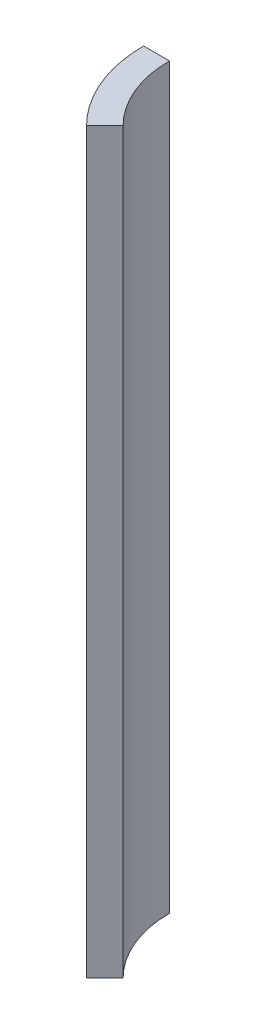
from build123d import *

# Parameters (mm, degrees)
BOSS_EXTRUDE1_DEPTH = 544.576


with BuildPart() as part:
    # Sketch1 → Boss-Extrude1 (new body)
    with BuildSketch(Plane(origin=(0, 0, 0), x_dir=(1, 0, 0), z_dir=(0, 1, 0))):
        with BuildLine():
            Line((-82.55, 0), (-101.6, 0))
            ThreePointArc((-101.6, 0), (-93.866160503, -38.880636728), (-71.842048969, -71.842048969))
            Line((-71.842048969, -71.842048969), (-58.371664787, -58.371664787))
            ThreePointArc((-58.371664787, -58.371664787), (-76.266255409, -31.590517342), (-82.55, 0))
        make_face()
    extrude(amount=BOSS_EXTRUDE1_DEPTH)


solid = part.part
